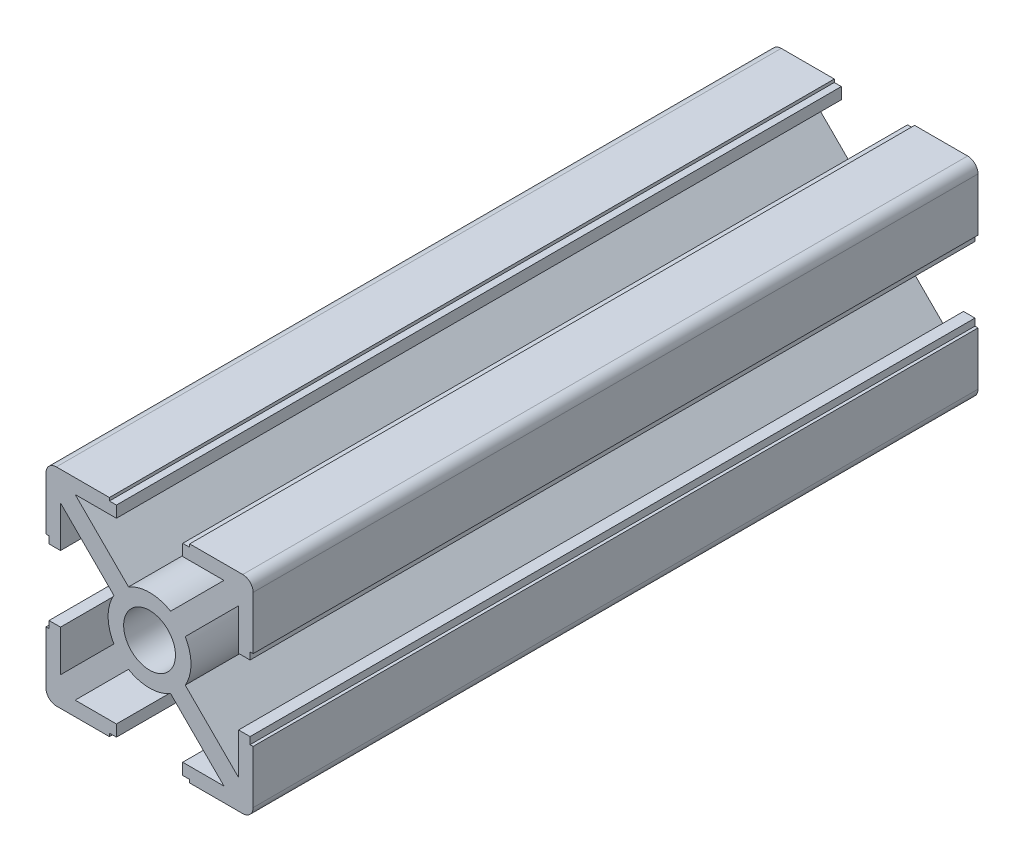
from build123d import *

# Parameters (mm, degrees)
SKETCH1_R           = 2.5
BOSS_EXTRUDE1_DEPTH = 70


with BuildPart() as part:
    # Sketch1 → Boss-Extrude1 (new body)
    with BuildSketch(Plane.XY):
        with BuildLine():
            Line((-9.707106781, -3.2), (-8.6, -3.2))
            Line((-8.6, -3.2), (-8.6, -7.185786438))
            Line((-8.6, -7.185786438), (-3.445719569, -2.031506006))
            ThreePointArc((-3.445719569, -2.031506006), (-4, 0), (-3.445719569, 2.031506006))
            Line((-3.445719569, 2.031506006), (-8.6, 7.185786438))
            Line((-8.6, 7.185786438), (-8.6, 3.2))
            Line((-8.6, 3.2), (-9.707106781, 3.2))
            Line((-9.707106781, 3.2), (-9.707106781, 3.877544562))
            Line((-9.707106781, 3.877544562), (-10, 3.877544562))
            Line((-10, 3.877544562), (-10, 9))
            ThreePointArc((-10, 9), (-9.707106781, 9.707106781), (-9, 10))
            Line((-9, 10), (-3.877544562, 10))
            Line((-3.877544562, 10), (-3.877544562, 9.707106781))
            Line((-3.877544562, 9.707106781), (-3.2, 9.707106781))
            Line((-3.2, 9.707106781), (-3.2, 8.6))
            Line((-3.2, 8.6), (-7.185786438, 8.6))
            Line((-7.185786438, 8.6), (-2.031506006, 3.445719569))
            ThreePointArc((-2.031506006, 3.445719569), (0, 4), (2.031506006, 3.445719569))
            Line((2.031506006, 3.445719569), (7.185786438, 8.6))
            Line((7.185786438, 8.6), (3.2, 8.6))
            Line((3.2, 8.6), (3.2, 9.707106781))
            Line((3.2, 9.707106781), (3.877544562, 9.707106781))
            Line((3.877544562, 9.707106781), (3.877544562, 10))
            Line((3.877544562, 10), (9, 10))
            ThreePointArc((9, 10), (9.707106781, 9.707106781), (10, 9))
            Line((10, 9), (10, 3.877544562))
            Line((10, 3.877544562), (9.707106781, 3.877544562))
            Line((9.707106781, 3.877544562), (9.707106781, 3.2))
            Line((9.707106781, 3.2), (8.6, 3.2))
            Line((8.6, 3.2), (8.6, 7.185786438))
            Line((8.6, 7.185786438), (3.445719569, 2.031506006))
            ThreePointArc((3.445719569, 2.031506006), (4, 0), (3.445719569, -2.031506006))
            Line((3.445719569, -2.031506006), (8.6, -7.185786438))
            Line((8.6, -7.185786438), (8.6, -3.2))
            Line((8.6, -3.2), (9.707106781, -3.2))
            Line((9.707106781, -3.2), (9.707106781, -3.877544562))
            Line((9.707106781, -3.877544562), (10, -3.877544562))
            Line((10, -3.877544562), (10, -9))
            ThreePointArc((10, -9), (9.707106781, -9.707106781), (9, -10))
            Line((9, -10), (3.877544562, -10))
            Line((3.877544562, -10), (3.877544562, -9.707106781))
            Line((3.877544562, -9.707106781), (3.2, -9.707106781))
            Line((3.2, -9.707106781), (3.2, -8.6))
            Line((3.2, -8.6), (7.185786438, -8.6))
            Line((7.185786438, -8.6), (2.031506006, -3.445719569))
            ThreePointArc((2.031506006, -3.445719569), (0, -4), (-2.031506006, -3.445719569))
            Line((-2.031506006, -3.445719569), (-7.185786438, -8.6))
            Line((-7.185786438, -8.6), (-3.2, -8.6))
            Line((-3.2, -8.6), (-3.2, -9.707106781))
            Line((-3.2, -9.707106781), (-3.877544562, -9.707106781))
            Line((-3.877544562, -9.707106781), (-3.877544562, -10))
            Line((-3.877544562, -10), (-9, -10))
            ThreePointArc((-9, -10), (-9.707106781, -9.707106781), (-10, -9))
            Line((-10, -9), (-10, -3.877544562))
            Line((-10, -3.877544562), (-9.707106781, -3.877544562))
            Line((-9.707106781, -3.877544562), (-9.707106781, -3.2))
        make_face()
        Circle(SKETCH1_R, mode=Mode.SUBTRACT)
    extrude(amount=BOSS_EXTRUDE1_DEPTH)


solid = part.part
